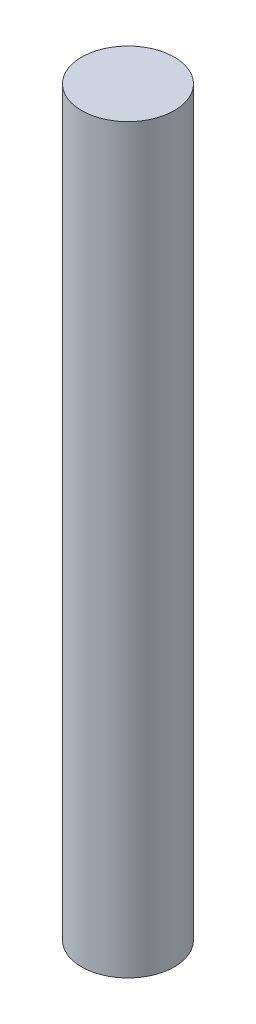
from build123d import *

# Parameters (mm, degrees)
SKETCH1_R           = 3.175
BOSS_EXTRUDE1_DEPTH = 50.8


with BuildPart() as part:
    # Sketch1 → Boss-Extrude1 (new body)
    with BuildSketch(Plane(origin=(0, 0, 0), x_dir=(1, 0, 0), z_dir=(0, 1, 0))):
        Circle(SKETCH1_R)
    extrude(amount=BOSS_EXTRUDE1_DEPTH)


solid = part.part
